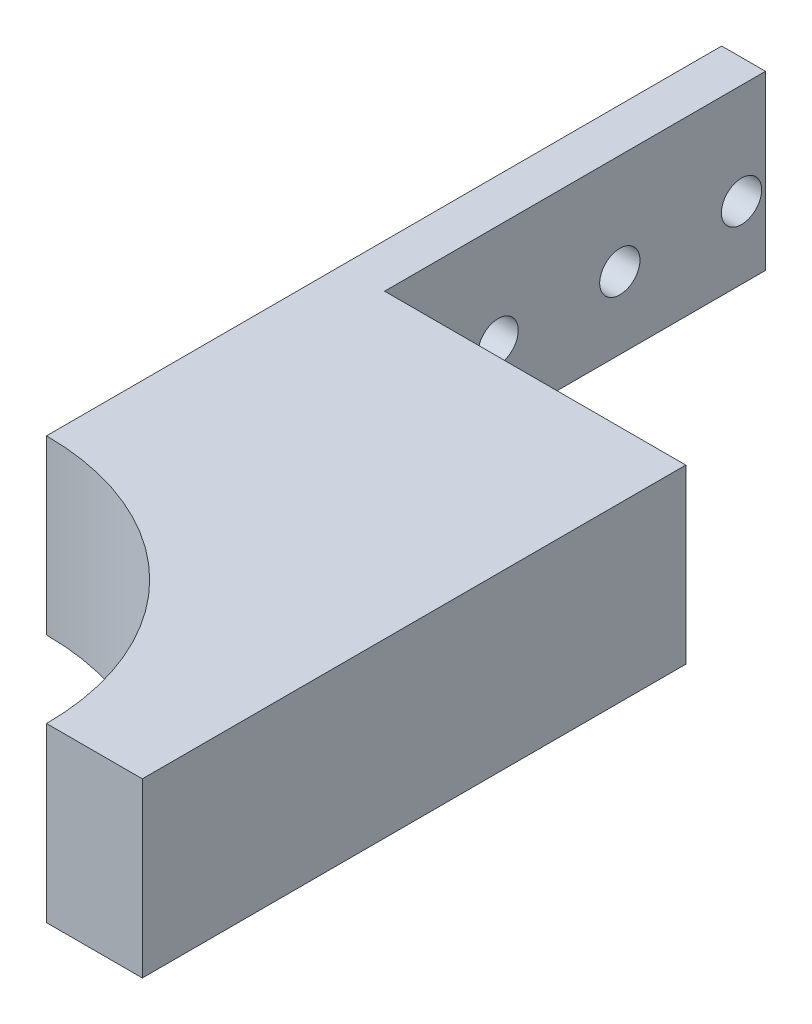
from build123d import *

# Parameters (mm, degrees)
BOSS_EXTRUDE1_DEPTH = 18
SKETCH4_R           = 2.1
CUT_EXTRUDE3_DEPTH  = 10


with BuildPart() as part:
    # Sketch1 → Boss-Extrude1 (new body)
    with BuildSketch(Plane(origin=(0, 0, 0), x_dir=(1, 0, 0), z_dir=(0, 1, 0))):
        with BuildLine():
            Line((-10, 0), (0, 0))
            Line((0, 0), (0, 56.712101031))
            Line((0, 56.712101031), (-31.43, 56.712101031))
            Line((-31.43, 56.712101031), (-31.43, 96.46))
            Line((-31.43, 96.46), (-36, 96.46))
            Line((-36, 96.46), (-36, 26))
            ThreePointArc((-36, 26), (-17.615223689, 18.384776311), (-10, 0))
        make_face()
    extrude(amount=BOSS_EXTRUDE1_DEPTH)

    # Sketch4 → Cut-Extrude3 (cut)
    with BuildSketch(Plane(origin=(-31.43, 0, 0), x_dir=(0, 0, -1), z_dir=(1, 0, 0))):
        with Locations((81.26, 7.5)):
            Circle(SKETCH4_R)
        with Locations((93.96, 7.5)):
            Circle(SKETCH4_R)
        with Locations((68.56, 7.5)):
            Circle(SKETCH4_R)
    extrude(amount=-CUT_EXTRUDE3_DEPTH, mode=Mode.SUBTRACT)


solid = part.part
